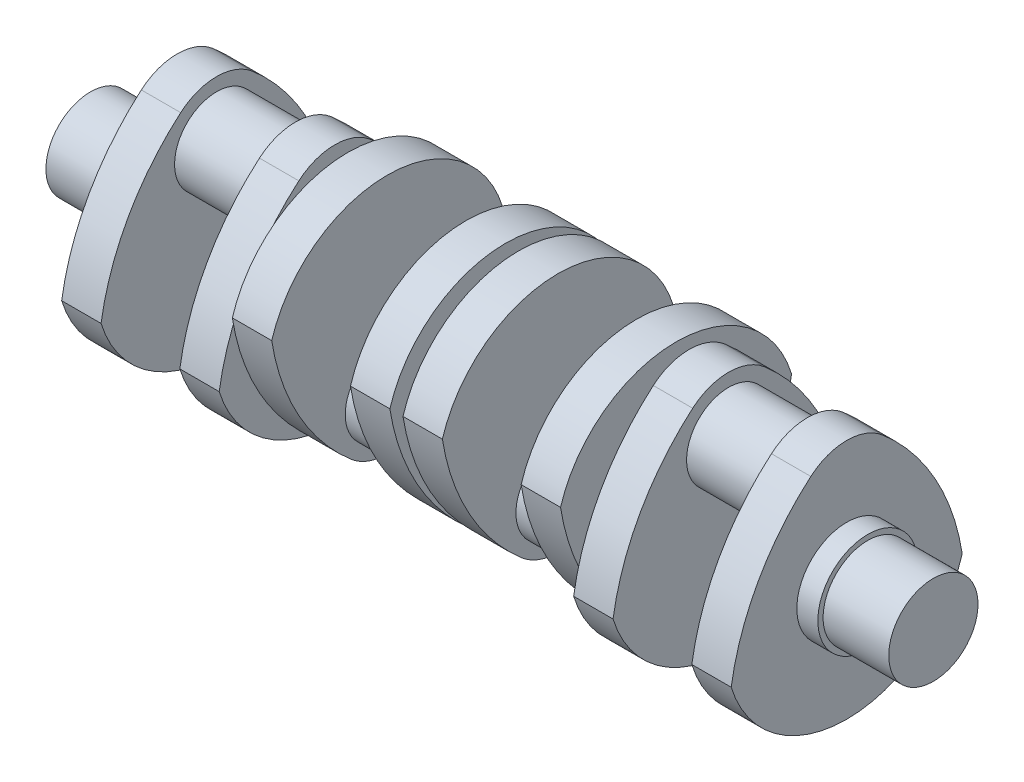
from build123d import *

# Parameters (mm, degrees)
SKETCH1_R           = 17
BOSS_EXTRUDE1_DEPTH = 25
SKETCH1_3_R         = 19
BOSS_EXTRUDE2_DEPTH = 8
BOSS_EXTRUDE3_DEPTH = 15
SKETCH3_R           = 16
BOSS_EXTRUDE4_DEPTH = 15
BOSS_EXTRUDE5_START = 5
SKETCH4_R           = 17
BOSS_EXTRUDE5_DEPTH = 5
BOSS_EXTRUDE6_DEPTH = 15
SKETCH6_R           = 16
BOSS_EXTRUDE7_DEPTH = 30
BOSS_EXTRUDE8_DEPTH = 15
BOSS_EXTRUDE9_START = 2.5
SKETCH8_R           = 17
BOSS_EXTRUDE9_DEPTH = 2.5


with BuildPart() as part:
    # Sketch1 → Boss-Extrude1 (new body)
    with BuildSketch(Plane(origin=(0, 0, 0), x_dir=(0, 0, -1), z_dir=(1, 0, 0))):
        Circle(SKETCH1_R)
    extrude(amount=-BOSS_EXTRUDE1_DEPTH)

    # Sketch1_3 → Boss-Extrude2 (add)
    with BuildSketch(Plane(origin=(0, 0, 0), x_dir=(0, 0, -1), z_dir=(1, 0, 0))):
        Circle(SKETCH1_3_R)
    extrude(amount=BOSS_EXTRUDE2_DEPTH)

    # Sketch2 → Boss-Extrude3 (add)
    with BuildSketch(Plane(origin=(8, 0, 0), x_dir=(0, 0, -1), z_dir=(1, 0, 0))):
        with BuildLine():
            ThreePointArc((-44, -13.416407865), (0, -46), (44, -13.416407865))
            ThreePointArc((44, -13.416407865), (33.683444249, 16.469257624), (13.668094758, 40.943123461))
            ThreePointArc((13.668094758, 40.943123461), (0, 46), (-13.668094758, 40.943123461))
            ThreePointArc((-13.668094758, 40.943123461), (-33.683444249, 16.469257624), (-44, -13.416407865))
        make_face()
    boss_extrude3 = extrude(amount=BOSS_EXTRUDE3_DEPTH)

    # Sketch3 → Boss-Extrude4 (add)
    with BuildSketch(Plane(origin=(23, 0, 0), x_dir=(0, 0, -1), z_dir=(1, 0, 0))):
        with Locations((0, 25)):
            Circle(SKETCH3_R)
    boss_extrude4 = extrude(amount=BOSS_EXTRUDE4_DEPTH)

    # Mirror1: Boss-Extrude3, Boss-Extrude4 across plane
    add(boss_extrude3.mirror(Plane(origin=(38, 25, 0), x_dir=(0, 0, 1), z_dir=(1, 0, 0))))
    add(boss_extrude4.mirror(Plane(origin=(38, 25, 0), x_dir=(0, 0, 1), z_dir=(1, 0, 0))))

    # Sketch4 → Boss-Extrude5 (add)
    with BuildSketch(Plane(origin=(68, 0, 0), x_dir=(0, 0, -1), z_dir=(1, 0, 0)).offset(BOSS_EXTRUDE5_START)):
        Circle(SKETCH4_R)
    extrude(amount=-BOSS_EXTRUDE5_DEPTH)

    # Sketch5 → Boss-Extrude6 (add)
    with BuildSketch(Plane(origin=(73, 0, 0), x_dir=(0, 0, -1), z_dir=(1, 0, 0))):
        with BuildLine():
            ThreePointArc((44, 13.416407865), (0, 46), (-44, 13.416407865))
            ThreePointArc((-44, 13.416407865), (-33.683444249, -16.469257624), (-13.668094758, -40.943123461))
            ThreePointArc((-13.668094758, -40.943123461), (0, -46), (13.668094758, -40.943123461))
            ThreePointArc((13.668094758, -40.943123461), (33.683444249, -16.469257624), (44, 13.416407865))
        make_face()
    extrude(amount=BOSS_EXTRUDE6_DEPTH)

    # Sketch6 → Boss-Extrude7 (add)
    with BuildSketch(Plane(origin=(88, 0, 0), x_dir=(0, 0, -1), z_dir=(1, 0, 0))):
        with Locations((0, -25)):
            Circle(SKETCH6_R)
    extrude(amount=BOSS_EXTRUDE7_DEPTH)

    # Sketch7 → Boss-Extrude8 (add)
    with BuildSketch(Plane(origin=(118, 0, 0), x_dir=(0, 0, -1), z_dir=(1, 0, 0))):
        with BuildLine():
            ThreePointArc((44, 13.416407865), (0, 46), (-44, 13.416407865))
            ThreePointArc((-44, 13.416407865), (-33.683444249, -16.469257624), (-13.668094758, -40.943123461))
            ThreePointArc((-13.668094758, -40.943123461), (0, -46), (13.668094758, -40.943123461))
            ThreePointArc((13.668094758, -40.943123461), (33.683444249, -16.469257624), (44, 13.416407865))
        make_face()
    extrude(amount=BOSS_EXTRUDE8_DEPTH)

    # Sketch8 → Boss-Extrude9 (add)
    with BuildSketch(Plane(origin=(133, 0, 0), x_dir=(0, 0, -1), z_dir=(1, 0, 0)).offset(BOSS_EXTRUDE9_START)):
        Circle(SKETCH8_R)
    extrude(amount=-BOSS_EXTRUDE9_DEPTH)

    # Mirror12: part across plane


with BuildPart() as part_1:
    add(part.part)
    add(part.part.mirror(Plane(origin=(135.5, 0, 0), x_dir=(0, 0, 1), z_dir=(1, 0, 0))))


solid = part_1.part
